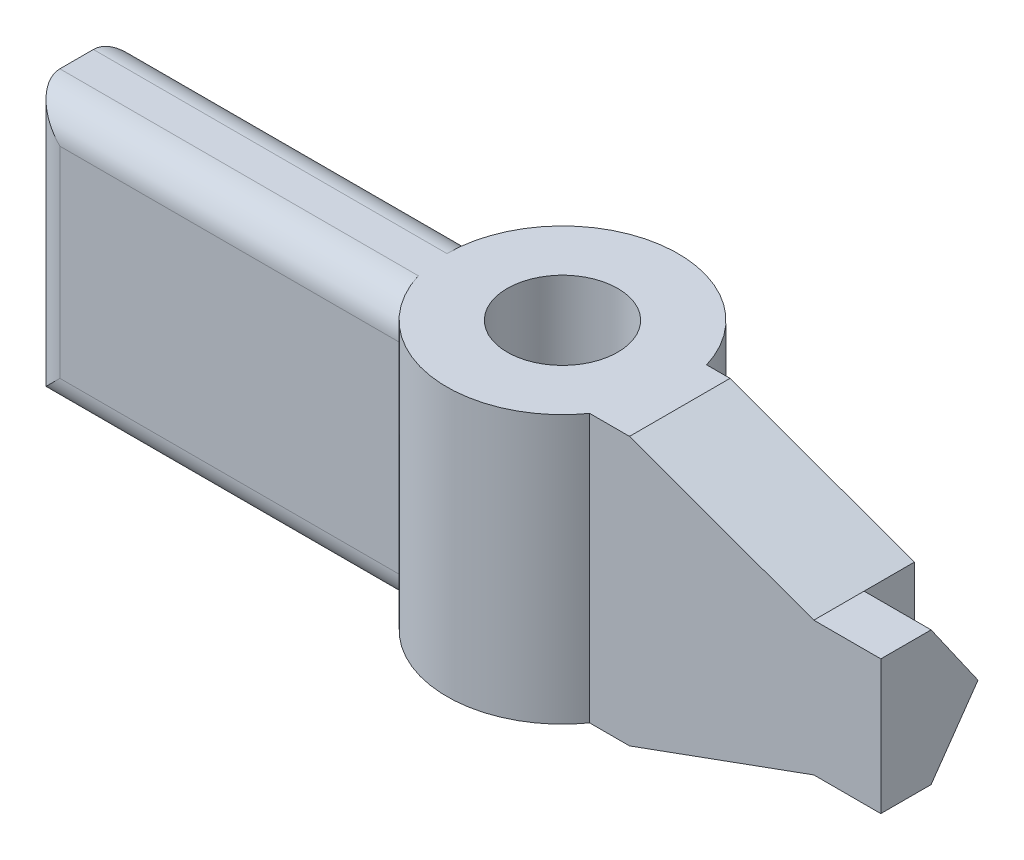
from build123d import *

# Parameters (mm, degrees)
BOSS_EXTRUDE1_DEPTH = 7
SKETCH2_R           = 1.65
CUT_EXTRUDE1_DEPTH  = 8
CUT_EXTRUDE2_DEPTH  = 2
FILLET1_R           = 1


with BuildPart() as part:
    # Sketch1 → Boss-Extrude1 (new body)
    with BuildSketch(Plane.XY):
        Polygon((-2.750000021, 4.000000393), (5.249999979, 4.000000393), (10.750000021, 2), (12.750000021, 2), (12.750000021, -1.999999214), (10.750000021, -1.999999214), (5.249999979, -3.999999607), (-2.750000021, -3.999999607), (-12.750000021, -3.999999607), (-12.750000021, 4.000000393), align=None)
    extrude(amount=BOSS_EXTRUDE1_DEPTH)

    # Sketch2 → Cut-Extrude1 (cut)
    with BuildSketch(Plane(origin=(0, 4.000000393, 0), x_dir=(1, 0, 0), z_dir=(0, 1, 0))):
        with Locations((1.249999979, -3.5)):
            Circle(SKETCH2_R)
        with BuildLine():
            Line((-12.750000021, -2.5), (-2.051893418, -2.5))
            ThreePointArc((-2.051893418, -2.5), (1.249999979, -0.05), (4.551893375, -2.5))
            Line((4.551893375, -2.5), (12.750000021, -2.5))
            Line((12.750000021, -2.5), (12.750000021, 0))
            Line((12.750000021, 0), (-12.750000021, 0))
            Line((-12.750000021, 0), (-12.750000021, -2.5))
        make_face()
        with BuildLine():
            Line((-12.750000021, -5.5), (-1.561138581, -5.5))
            ThreePointArc((-1.561138581, -5.5), (1.249999979, -6.95), (4.061138538, -5.5))
            Line((4.061138538, -5.5), (12.750000021, -5.5))
            Line((12.750000021, -5.5), (12.750000021, -7))
            Line((12.750000021, -7), (-12.750000021, -7))
            Line((-12.750000021, -7), (-12.750000021, -5.5))
        make_face()
    extrude(amount=-CUT_EXTRUDE1_DEPTH, mode=Mode.SUBTRACT)

    # Sketch3 → Cut-Extrude2 (cut)
    with BuildSketch(Plane(origin=(12.750000021, 0, 0), x_dir=(0, 0, -1), z_dir=(1, 0, 0))):
        Polygon((-4, 2), (-2.6, 0), (-4, -2), (-2.5, -2), (-2.5, 0), (-2.5, 2), align=None)
    extrude(amount=-CUT_EXTRUDE2_DEPTH, mode=Mode.SUBTRACT)

    # Fillet1
    fillet1_edges = [part.edges().sort_by_distance(p)[0] for p in [
        (-7.40094672, 4.000000393, 2.5),
        (-7.40094672, -3.999999607, 2.5),
        (-12.750000021, 3.93e-07, 2.5),
        (-7.155569301, 4.000000393, 5.5),
        (-7.155569301, -3.999999607, 5.5),
        (-12.750000021, 3.93e-07, 5.5),
    ]]
    fillet(fillet1_edges, radius=FILLET1_R)


solid = part.part
